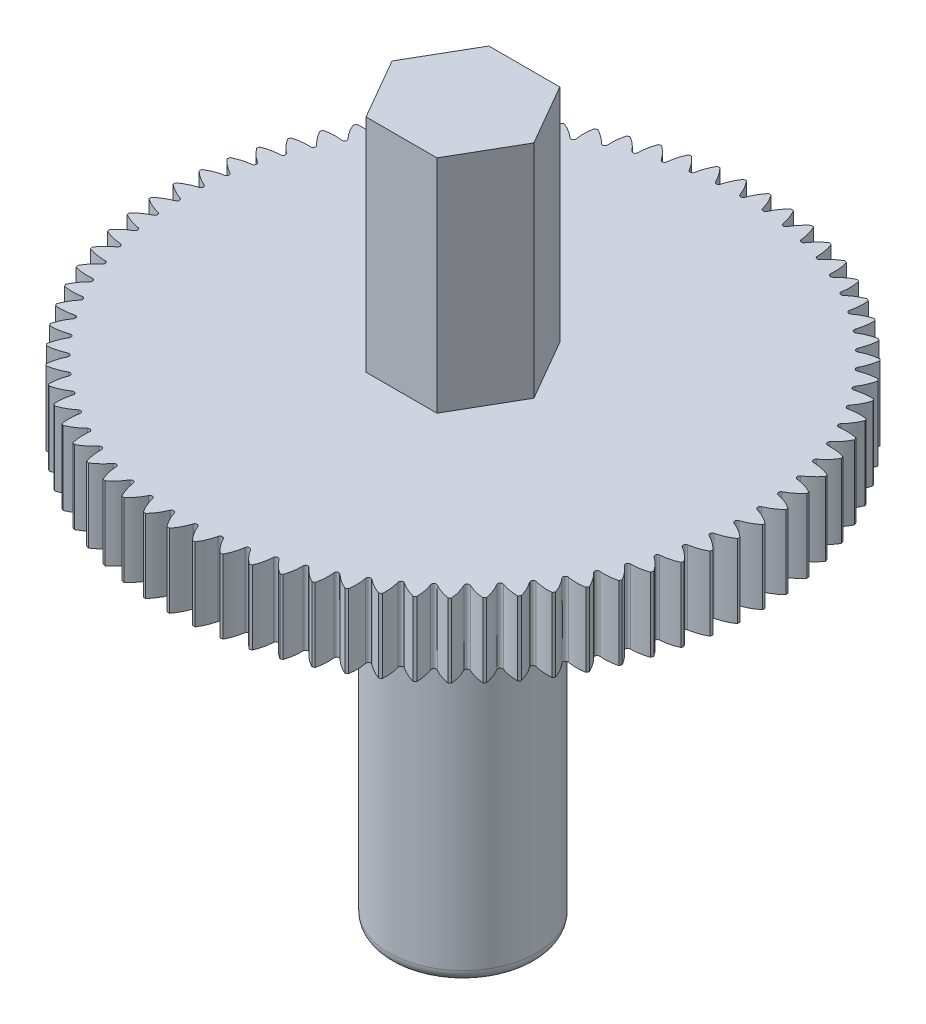
from build123d import *

# Parameters (mm, degrees)
FILLET1_R          = 0.5
SKETCH3_R          = 3
CUT_EXTRUDE1_DEPTH = 9
CUT_EXTRUDE2_DEPTH = 3
CIRPATTERN1_COUNT  = 75


with BuildPart() as part:
    # Sketch2 → Revolve1 (revolve)
    with BuildSketch(Plane.XY):
        Polygon((0, 0), (0, 29), (3, 29), (3, 20), (12, 20), (12, 17), (3, 17), (3, 0), align=None)
    revolve(axis=Axis((0, 0, 0), (0, 1, 0)))

    # Fillet1
    fillet1_edges = [part.edges().sort_by_distance(p)[0] for p in [
        (-3, 0, 0),
    ]]
    fillet(fillet1_edges, radius=FILLET1_R)

    # Sketch3 → Cut-Extrude1 (cut)
    with BuildSketch(Plane(origin=(0, 29, 0), x_dir=(1, 0, 0), z_dir=(0, 1, 0))):
        Circle(SKETCH3_R)
        Polygon((1.443375673, 2.5), (-1.443375673, 2.5), (-2.886751346, 0), (-1.443375673, -2.5), (1.443375673, -2.5), (2.886751346, 0), align=None, mode=Mode.SUBTRACT)
    extrude(amount=-CUT_EXTRUDE1_DEPTH, mode=Mode.SUBTRACT)

    # Sketch4 → Cut-Extrude2 (cut)
    with BuildSketch(Plane(origin=(0, 20, 0), x_dir=(1, 0, 0), z_dir=(0, 1, 0))):
        with BuildLine():
            ThreePointArc((-0.45, 11.991559532), (-0.244185037, 11.69752696), (-0.094236566, 11.371443523))
            ThreePointArc((-0.094236566, 11.371443523), (0, 11.304902), (0.094236566, 11.371443523))
            ThreePointArc((0.094236566, 11.371443523), (0.244185037, 11.69752696), (0.45, 11.991559532))
            ThreePointArc((0.45, 11.991559532), (0, 12), (-0.45, 11.991559532))
        make_face()
    cut_extrude2 = extrude(amount=-CUT_EXTRUDE2_DEPTH, mode=Mode.SUBTRACT)

    # CirPattern1: Cut-Extrude2 ×75 about axis
    cirpattern1_axis = Axis((0, 0, 0), (0, 1, 0))
    for i in range(1, CIRPATTERN1_COUNT):
        add(cut_extrude2.rotate(cirpattern1_axis, i * 360 / CIRPATTERN1_COUNT), mode=Mode.SUBTRACT)


solid = part.part
